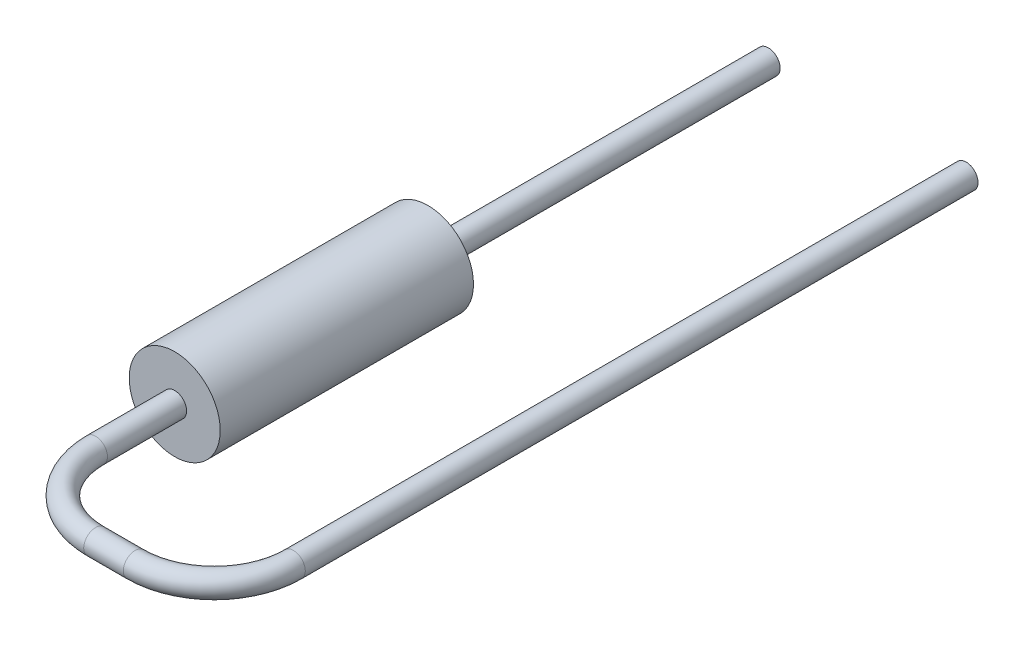
from build123d import *

# Parameters (mm, degrees)
SKETCH2_R           = 1.15
RESISTOR_BODY_DEPTH = 6.4
LEAD1_PROFILE_R     = 0.3
SKETCH6_R           = 0.3
LEAD2_DEPTH         = 8.6


with BuildPart() as part:
    # Sketch2 → Resistor Body (new body)
    with BuildSketch(Plane.XY):
        Circle(SKETCH2_R)
    extrude(amount=RESISTOR_BODY_DEPTH)

    # Lead1: sweep along a path in Lead1 Path
    with BuildLine(Plane.XZ) as lead1_path:
        Line((0, 6.4), (0, 8.4))
        ThreePointArc((0, 8.4), (0.585786438, 9.814213562), (2, 10.4))
        Line((2, 10.4), (3, 10.4))
        ThreePointArc((3, 10.4), (4.414213562, 9.814213562), (5, 8.4))
        Line((5, 8.4), (5, -8.6))
    # Lead1 Profile → Lead1 (sweep)
    with BuildSketch(Plane(origin=(0, 0, 6.4), x_dir=(-1, 0, 0), z_dir=(0, 0, 1))):
        Circle(LEAD1_PROFILE_R)
    sweep(path=lead1_path.line)

    # Sketch6 → Lead2 (add)
    with BuildSketch(Plane(origin=(0, 0, 0), x_dir=(1, 0, 0), z_dir=(0, 0, -1))):
        Circle(SKETCH6_R)
    extrude(amount=LEAD2_DEPTH)


solid = part.part
